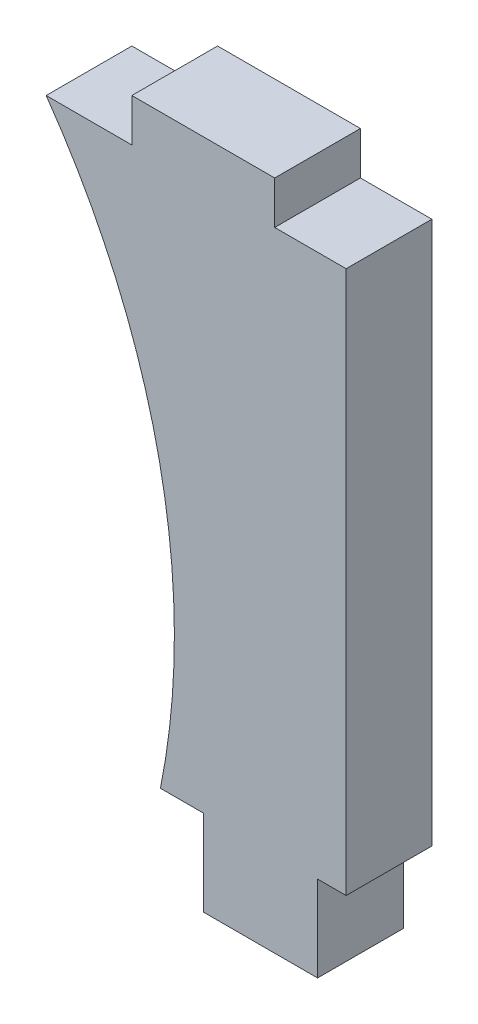
from build123d import *

# Parameters (mm, degrees)
SALIENTE_EXTRUIR1_DEPTH = 3


with BuildPart() as part:
    # Croquis2 → Saliente-Extruir1 (new body)
    with BuildSketch(Plane.XY):
        with BuildLine():
            Line((-1.5, 0), (0, 0))
            Line((0, 0), (0, -3))
            Line((0, -3), (4, -3))
            Line((4, -3), (4, 0))
            Line((4, 0), (5, 0))
            Line((5, 0), (5, 19))
            Line((5, 19), (2.5, 19))
            Line((2.5, 19), (2.5, 20.5))
            Line((2.5, 20.5), (-2.5, 20.5))
            Line((-2.5, 20.5), (-2.5, 19))
            Line((-2.5, 19), (-5.5, 19))
            ThreePointArc((-5.5, 19), (-1.537463371, 9.913165606), (-1.5, 0))
        make_face()
    extrude(amount=SALIENTE_EXTRUIR1_DEPTH)


solid = part.part
